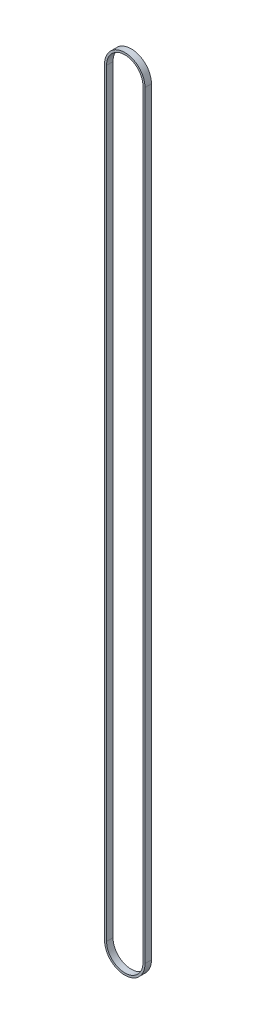
from build123d import *

# Parameters (mm, degrees)
EXTRUDE_THIN1_DEPTH = 3.175


with BuildPart() as part:
    # Sketch1 → Extrude-Thin1 (new body)
    with BuildSketch(Plane.XY):
        with BuildLine():
            Line((-10, 0), (-10, 375))
            ThreePointArc((-10, 375), (0, 385), (10, 375))
            Line((10, 375), (10, 0))
            ThreePointArc((10, 0), (0, -10), (-10, 0))
        make_face()
        with BuildLine():
            Line((-9, 0), (-9, 375))
            ThreePointArc((-9, 375), (0, 384), (9, 375))
            Line((9, 375), (9, 0))
            ThreePointArc((9, 0), (0, -9), (-9, 0))
        make_face(mode=Mode.SUBTRACT)
    extrude(amount=EXTRUDE_THIN1_DEPTH)


solid = part.part
